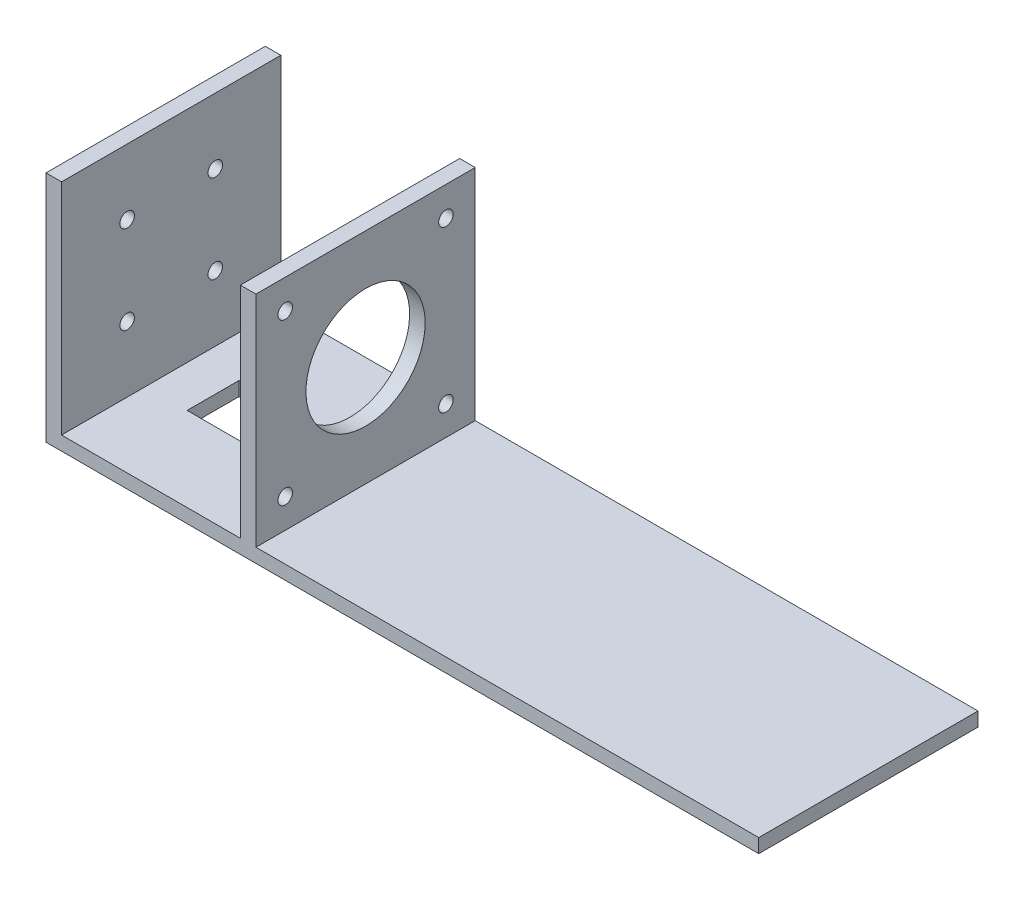
from build123d import *

# Parameters (mm, degrees)
BOSS_EXTRUDE1_DEPTH = 42.3
SKETCH3_R           = 11.5
SKETCH3_R_2         = 1.4
CUT_EXTRUDE1_DEPTH  = 5
SKETCH4_R           = 1.4
CUT_EXTRUDE2_DEPTH  = 5
SKETCH5_W           = 20
SKETCH5_H           = 10
CUT_EXTRUDE3_DEPTH  = 5


with BuildPart() as part:
    # Sketch2 → Boss-Extrude1 (new body)
    with BuildSketch(Plane.XY):
        Polygon((-2.75, 22.5), (-2.75, -19.8), (-37.25, -19.8), (-37.25, 22.5), (-40.25, 22.5), (-40.25, -22.5), (97.25, -22.5), (97.25, -19.8), (0.25, -19.8), (0.25, 22.5), align=None)
    extrude(amount=BOSS_EXTRUDE1_DEPTH)

    # Sketch3 → Cut-Extrude1 (cut)
    with BuildSketch(Plane(origin=(0.25, 0, 0), x_dir=(0, 0, -1), z_dir=(1, 0, 0))):
        with Locations((-21.15, 1.35)):
            Circle(SKETCH3_R)
        with Locations((-36.65, 16.85)):
            Circle(SKETCH3_R_2)
        with Locations((-5.65, 16.85)):
            Circle(SKETCH3_R_2)
        with Locations((-5.65, -14.15)):
            Circle(SKETCH3_R_2)
        with Locations((-36.65, -14.15)):
            Circle(SKETCH3_R_2)
    extrude(amount=-CUT_EXTRUDE1_DEPTH, mode=Mode.SUBTRACT)

    # Sketch4 → Cut-Extrude2 (cut)
    with BuildSketch(Plane(origin=(-37.25, 0, 0), x_dir=(0, 0, -1), z_dir=(1, 0, 0))):
        with Locations((-29.65, 9.85)):
            Circle(SKETCH4_R)
        with Locations((-12.65, 9.85)):
            Circle(SKETCH4_R)
        with Locations((-12.65, -7.15)):
            Circle(SKETCH4_R)
        with Locations((-29.65, -7.15)):
            Circle(SKETCH4_R)
    extrude(amount=-CUT_EXTRUDE2_DEPTH, mode=Mode.SUBTRACT)

    # Sketch5 → Cut-Extrude3 (cut)
    with BuildSketch(Plane(origin=(0, -19.8, 0), x_dir=(1, 0, 0), z_dir=(0, 1, 0))):
        with Locations((-19.25, -21.070122094)):
            Rectangle(SKETCH5_W, SKETCH5_H)
    extrude(amount=-CUT_EXTRUDE3_DEPTH, mode=Mode.SUBTRACT)


solid = part.part
